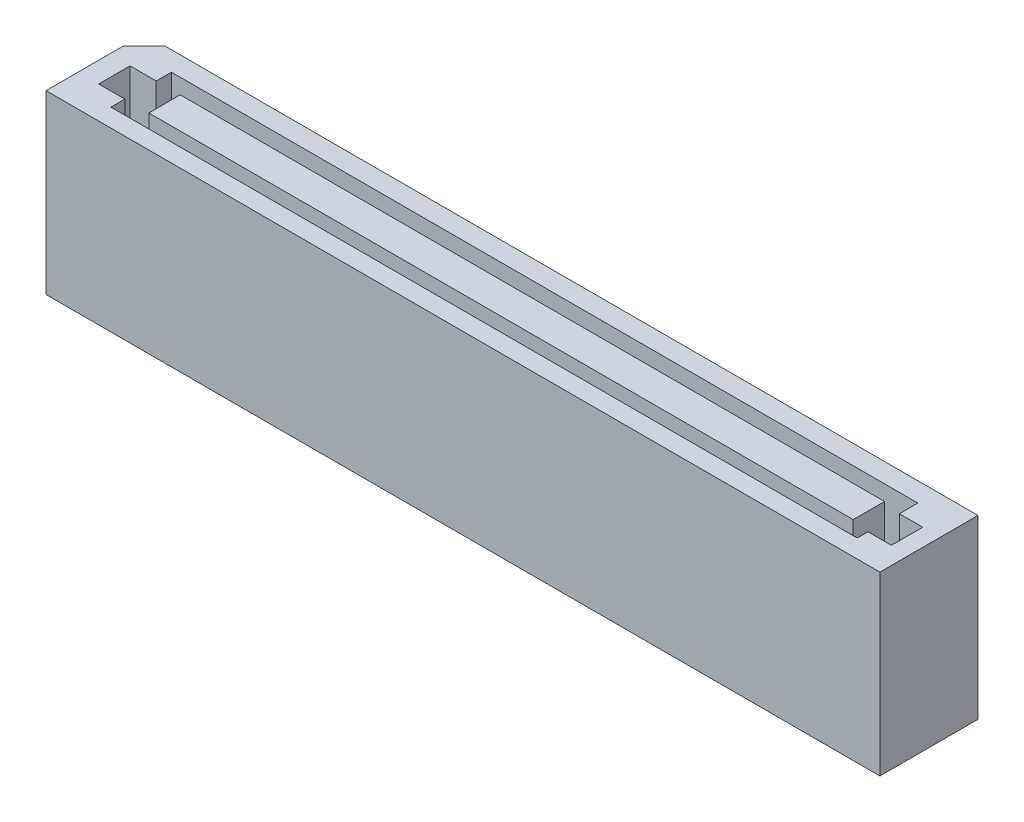
from build123d import *

# Parameters (mm, degrees)
SV_DEPTH           = 9
SKETCH3_W          = 35.897762959
SKETCH3_H          = 1.597828601
CUT_EXTRUDE1_DEPTH = 3.5


with BuildPart() as part:
    # Sketch1 → SV (new body)
    with BuildSketch(Plane(origin=(0, 0, 0), x_dir=(1, 0, 0), z_dir=(0, 1, 0))):
        Polygon((-20.189, 2.5), (21.25, 2.5), (21.25, -1.44), (21.25, -2.5), (20.19, -2.5), (-21.25, -2.5), (-21.25, 1.439), align=None)
    extrude(amount=SV_DEPTH)

    # Sketch3 → Cut-Extrude1 (cut)
    with BuildSketch(Plane(origin=(0, 9, 0), x_dir=(1, 0, 0), z_dir=(0, 1, 0))):
        Polygon((-20.202517392, 0.734832739), (-18.867516597, 0.734832739), (-18.867516597, 1.51327079), (19.169882457, 1.51327079), (19.169882457, 0.573528463), (20.36118295, 0.573528463), (20.36118295, -1.024300139), (19.169882457, -1.024300139), (19.169882457, -1.572342426), (-18.867516597, -1.572342426), (-18.867516597, -0.862995862), (-20.202517392, -0.862995862), align=None)
        with Locations((0.304154287, -0.064081561)):
            Rectangle(SKETCH3_W, SKETCH3_H, mode=Mode.SUBTRACT)
    extrude(amount=-CUT_EXTRUDE1_DEPTH, mode=Mode.SUBTRACT)


solid = part.part
